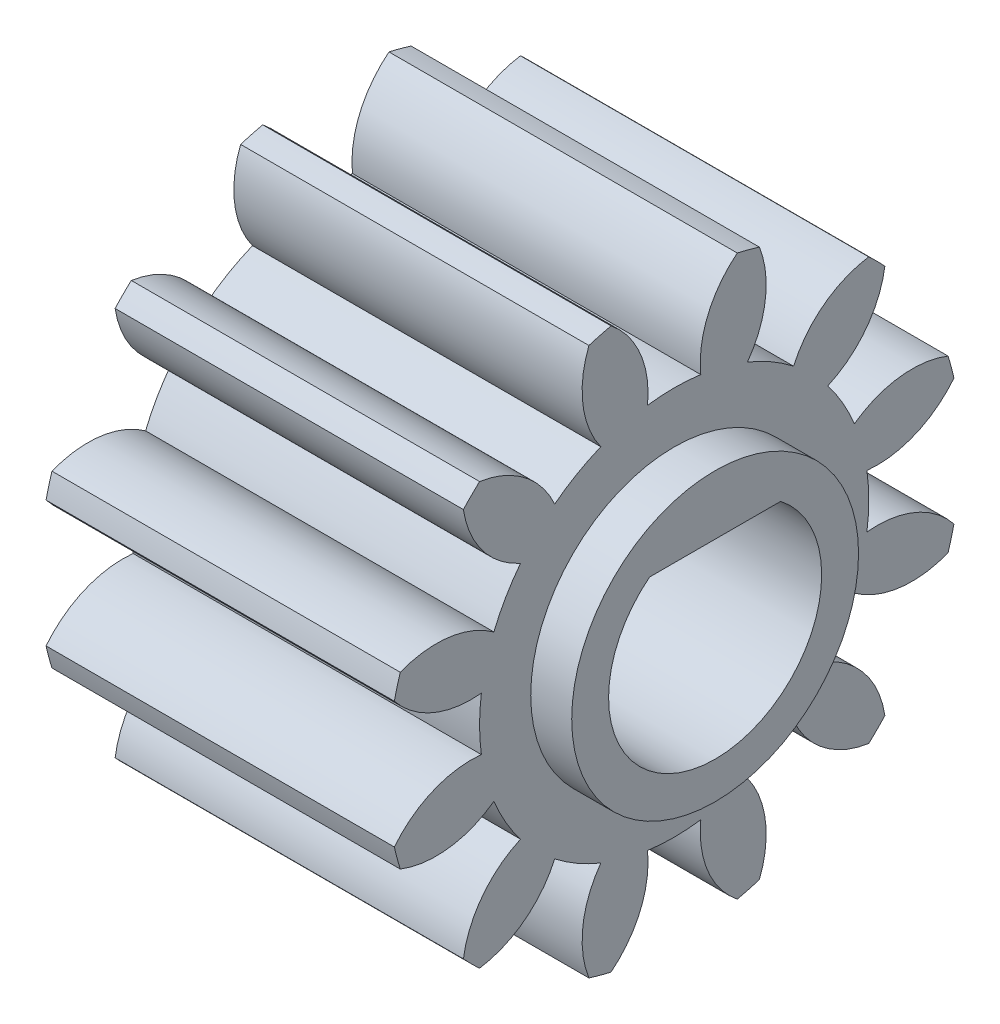
from build123d import *

# Parameters (mm, degrees)
BASPROSKE_W         = 8.5
BASPROSKE_H         = 7
TOOTHCUT_DEPTH      = 14.047988351
TEETHCUTS_COUNT     = 12
TEETHCUTS_ANGLE     = 330
BORSKE_R            = 2.6
BORE_DEPTH          = 50.0000508
BOSS_EXTRUDE1_DEPTH = 8.5
SKETCH2_R           = 3.5
BOSS_EXTRUDE2_DEPTH = 1


with BuildPart() as part:
    # BasProSke → Base-Revolve (revolve)
    with BuildSketch(Plane(origin=(0, 0, 0), x_dir=(1, 0, 0), z_dir=(0, 1, 0)), mode=Mode.PRIVATE) as base_revolve_sk:
        with Locations((4.25, 3.5)):
            Rectangle(BASPROSKE_W, BASPROSKE_H)
    revolve(base_revolve_sk.sketch.rotate(Axis((-10, 0, 0), (1, 0, 0)), 180), axis=Axis((-10, 0, 0), (1, 0, 0)))

    # TooCutSke → ToothCut (cut, through all)
    with BuildSketch(Plane(origin=(0, 0, 0), x_dir=(0, 0, -1), z_dir=(1, 0, 0))):
        with BuildLine():
            ThreePointArc((0.649675465, 4.704351474), (0, 4.749), (-0.649675465, 4.704351474))
            ThreePointArc((-0.649675465, 4.704351474), (-0.830100462, 5.895273832), (-1.56637772, 6.84855503))
            ThreePointArc((-1.56637772, 6.84855503), (0, 7.0254), (1.56637772, 6.84855503))
            ThreePointArc((1.56637772, 6.84855503), (0.830100462, 5.895273832), (0.649675465, 4.704351474))
        make_face()
    toothcut = extrude(amount=TOOTHCUT_DEPTH, mode=Mode.SUBTRACT)

    # TeethCuts: ToothCut ×12 about axis
    teethcuts_axis = Axis((-10, 0, 0), (1, 0, 0))
    for i in range(1, TEETHCUTS_COUNT):
        add(toothcut.rotate(teethcuts_axis, i * TEETHCUTS_ANGLE / (TEETHCUTS_COUNT - 1)), mode=Mode.SUBTRACT)

    # BorSke → Bore (cut, symmetric)
    with BuildSketch(Plane(origin=(0, 0, 0), x_dir=(0, 0, -1), z_dir=(1, 0, 0))):
        with Locations(Location((0, 0, 0), (0, 0, 180))):
            Circle(BORSKE_R)
    extrude(amount=BORE_DEPTH, both=True, mode=Mode.SUBTRACT)

    # Sketch1 → Boss-Extrude1 (add)
    with BuildSketch(Plane(origin=(8.5, 0, 0), x_dir=(0, 0, -1), z_dir=(1, 0, 0))):
        with BuildLine():
            Line((-1.599218559, 2.05), (1.599218559, 2.05))
            ThreePointArc((1.599218559, 2.05), (0, 2.6), (-1.599218559, 2.05))
        make_face()
    extrude(amount=-BOSS_EXTRUDE1_DEPTH)

    # Sketch2 → Boss-Extrude2 (add)
    with BuildSketch(Plane(origin=(8.5, 0, 0), x_dir=(0, 0, -1), z_dir=(1, 0, 0))):
        with Locations(Location((0, 0, 0), (0, 0, 180))):
            Circle(SKETCH2_R)
        with BuildLine():
            Line((-1.599218559, 2.05), (1.599218559, 2.05))
            ThreePointArc((1.599218559, 2.05), (0, -2.6), (-1.599218559, 2.05))
        make_face(mode=Mode.SUBTRACT)
    extrude(amount=BOSS_EXTRUDE2_DEPTH)


solid = part.part
